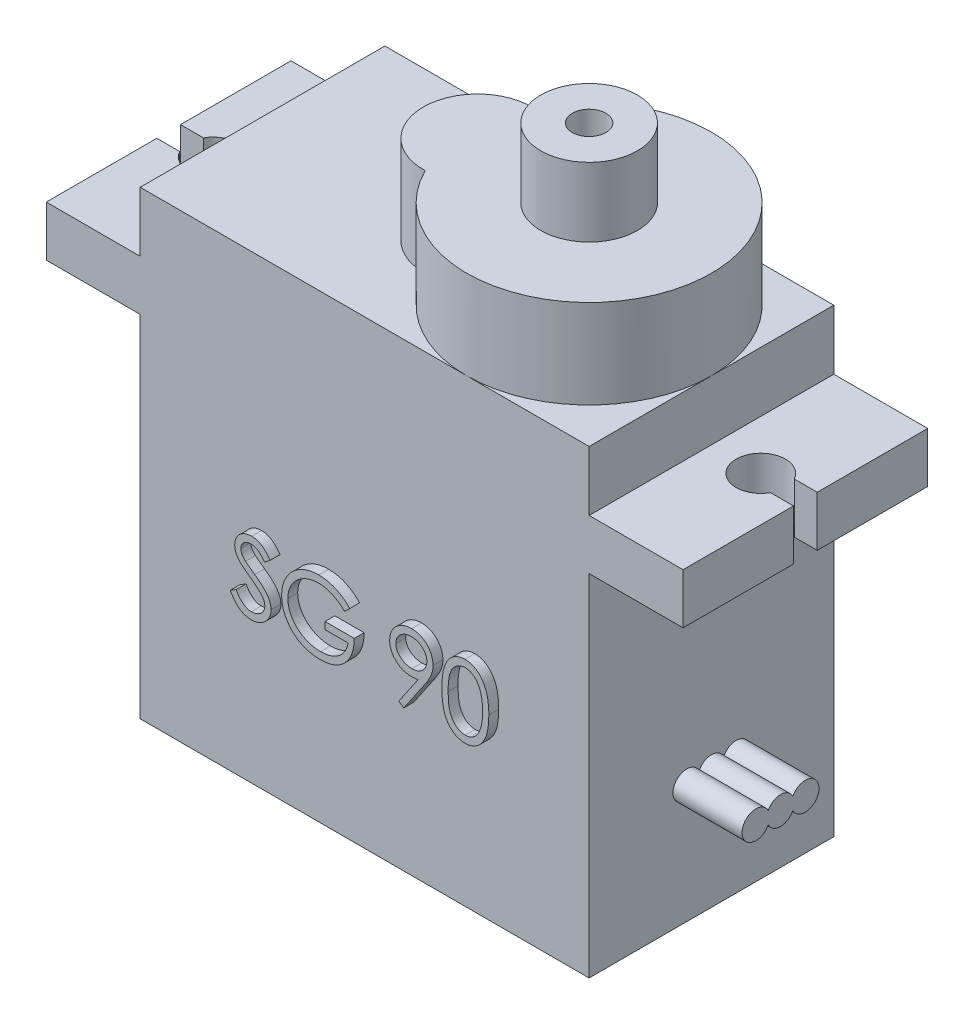
from build123d import *

# Parameters (mm, degrees)
SALIENTE_EXTRUIR1_DEPTH = 6.2
SALIENTE_EXTRUIR2_START = 5.58
CROQUIS2_R              = 6.2
CROQUIS2_R_2            = 2.75
SALIENTE_EXTRUIR2_DEPTH = 4.5
SALIENTE_EXTRUIR3_START = 10.08
CROQUIS3_R              = 2.45
CROQUIS3_R_2            = 0.85
SALIENTE_EXTRUIR3_DEPTH = 3.5
SALIENTE_EXTRUIR5_START = 11.375
CROQUIS4_R              = 0.7
SALIENTE_EXTRUIR5_DEPTH = 3.5
CROQUIS5_R              = 1.25
CROQUIS5_W              = 3.02368951
CROQUIS5_H              = 1.2
CORTAR_EXTRUIR1_DEPTH   = 3.5
CORTAR_EXTRUIR2_START   = -17.75
CORTAR_EXTRUIR2_DEPTH   = 0.5
SALIENTE_EXTRUIR6_START = 6.2
SALIENTE_EXTRUIR6_DEPTH = 0.5


with BuildPart() as part:
    # Croquis1 → Saliente-Extruir1 (new body, symmetric)
    with BuildSketch(Plane.XY):
        Polygon((-11.375, 0), (-16.135, 0), (-16.135, 2.55), (-11.375, 2.55), (-11.375, 5.58), (11.375, 5.58), (11.375, 2.55), (16.135, 2.55), (16.135, 0), (11.375, 0), (11.375, -17.75), (-11.375, -17.75), align=None)
    extrude(amount=SALIENTE_EXTRUIR1_DEPTH, both=True)

    # Croquis2 → Saliente-Extruir2 (add)
    with BuildSketch(Plane(origin=(0, 0, 0), x_dir=(1, 0, 0), z_dir=(0, 1, 0)).offset(SALIENTE_EXTRUIR2_START)):
        with Locations((5.175, 0)):
            Circle(CROQUIS2_R)
        with Locations((-0.475, 0)):
            Circle(CROQUIS2_R_2)
    extrude(amount=SALIENTE_EXTRUIR2_DEPTH)

    # Croquis3 → Saliente-Extruir3 (add)
    with BuildSketch(Plane(origin=(0, 0, 0), x_dir=(1, 0, 0), z_dir=(0, 1, 0)).offset(SALIENTE_EXTRUIR3_START)):
        with Locations((5.175, 0)):
            Circle(CROQUIS3_R)
        with Locations((5.175, 0)):
            Circle(CROQUIS3_R_2, mode=Mode.SUBTRACT)
    extrude(amount=SALIENTE_EXTRUIR3_DEPTH)

    # Croquis4 → Saliente-Extruir5 (add)
    with BuildSketch(Plane(origin=(0, 0, 0), x_dir=(0, 0, -1), z_dir=(1, 0, 0)).offset(SALIENTE_EXTRUIR5_START)):
        with Locations((0, -11.75)):
            Circle(CROQUIS4_R)
        with Locations((1.25, -11.75)):
            Circle(CROQUIS4_R)
        with Locations((-1.25, -11.75)):
            Circle(CROQUIS4_R)
    extrude(amount=SALIENTE_EXTRUIR5_DEPTH)

    # Croquis5 → Cortar-Extruir1 (cut)
    with BuildSketch(Plane(origin=(0, 0, 0), x_dir=(1, 0, 0), z_dir=(0, 1, 0))):
        with Locations((-13.875, 0)):
            Circle(CROQUIS5_R)
        with Locations((-16.135, 0)):
            Rectangle(CROQUIS5_W, CROQUIS5_H)
    cortar_extruir1 = extrude(amount=CORTAR_EXTRUIR1_DEPTH, mode=Mode.SUBTRACT)

    # Simetría1: Cortar-Extruir1 across plane
    add(cortar_extruir1.mirror(Plane(origin=(0, 0, 0), x_dir=(0, 0, 1), z_dir=(1, 0, 0))), mode=Mode.SUBTRACT)

    # Croquis6 → Cortar-Extruir2 (cut)
    with BuildSketch(Plane(origin=(0, 0, 0), x_dir=(1, 0, 0), z_dir=(0, 1, 0)).offset(CORTAR_EXTRUIR2_START)):
        Polygon((1.883315853, 1.665238112), (1.569213289, 1.665238112), (1.569213289, -1.475787529), (0.223059443, -1.475787529), (0.223059443, -1.834761888), (1.883315853, -1.834761888), align=None)
        Polygon((-0.180786711, -1.834761888), (-0.642825974, 1.665238112), (-0.687697769, 1.665238112), (-2.132709788, -1.20655676), (-3.574216198, 1.665238112), (-3.619789115, 1.665238112), (-4.084632865, -1.834761888), (-3.769128057, -1.834761888), (-3.433991839, 0.683667599), (-2.170570365, -1.834761888), (-2.099757064, -1.834761888), (-0.831427737, 0.689276573), (-0.496992641, -1.834761888), align=None)
    extrude(amount=CORTAR_EXTRUIR2_DEPTH, mode=Mode.SUBTRACT)

    # Croquis7 → Saliente-Extruir6 (add)
    with BuildSketch(Plane.XY.offset(SALIENTE_EXTRUIR6_START)):
        with BuildLine():
            Line((-6.31025641, -9.324819712), (-6.014383013, -9.147435897))
            add(Edge.make_bspline(
                [(-6.014383013, -9.147435897), (-5.986864776, -9.193500282), (-5.934140895, -9.281757866), (-5.846189536, -9.401015907), (-5.755056625, -9.502378063), (-5.660067291, -9.585254671), (-5.561801343, -9.650503558), (-5.459617289, -9.696705789), (-5.353859479, -9.725521765), (-5.281885657, -9.729021851), (-5.245953526, -9.730769231)],
                knots=[0, 0, 0, 0, 0.000160901, 0.00030828, 0.000443778, 0.00056903, 0.000685513, 0.000796284, 0.00090427, 0.001011928, 0.001011928, 0.001011928, 0.001011928], degree=3))
            add(Edge.make_bspline(
                [(-5.245953526, -9.730769231), (-5.215266665, -9.729914558), (-5.154429892, -9.728220168), (-5.064867649, -9.711939366), (-4.977885847, -9.686927237), (-4.895277209, -9.651106306), (-4.818181595, -9.60776782), (-4.750574899, -9.555421642), (-4.692128786, -9.496815437), (-4.644319672, -9.431432782), (-4.607639636, -9.361115633), (-4.579447568, -9.288939682), (-4.563802494, -9.213771114), (-4.561445741, -9.163160651), (-4.56025641, -9.137620192)],
                knots=[0, 0, 0, 0, 9.1978e-05, 0.000182347, 0.000272202, 0.000362975, 0.000451852, 0.000536835, 0.000618639, 0.000699414, 0.000778765, 0.000855983, 0.0009312, 0.001007828, 0.001007828, 0.001007828, 0.001007828], degree=3))
            add(Edge.make_bspline(
                [(-4.56025641, -9.137620192), (-4.561730721, -9.108479343), (-4.564727779, -9.049240253), (-4.590059259, -8.9618406), (-4.629908506, -8.87534803), (-4.66667115, -8.821846765), (-4.685757212, -8.794070513)],
                knots=[0, 0, 0, 0, 8.7281e-05, 0.000177429, 0.000270909, 0.000371844, 0.000371844, 0.000371844, 0.000371844], degree=3))
            add(Edge.make_bspline(
                [(-4.685757212, -8.794070513), (-4.701427826, -8.774023689), (-4.73432632, -8.731937891), (-4.790883833, -8.669292655), (-4.857249947, -8.604674236), (-4.931153502, -8.535615179), (-5.015286591, -8.465327383), (-5.107014105, -8.390459105), (-5.208677964, -8.313857528), (-5.279977461, -8.262484962), (-5.316766827, -8.235977564)],
                knots=[0, 0, 0, 0, 7.6319e-05, 0.000160223, 0.000252933, 0.000354147, 0.000463581, 0.000581729, 0.000709336, 0.000845369, 0.000845369, 0.000845369, 0.000845369], degree=3))
            add(Edge.make_bspline(
                [(-5.316766827, -8.235977564), (-5.353590823, -8.209748976), (-5.4239955, -8.159601914), (-5.522454082, -8.08517763), (-5.610498545, -8.017133761), (-5.687737562, -7.954829749), (-5.754137158, -7.898257144), (-5.810220569, -7.847959205), (-5.854559127, -7.802575644), (-5.879214707, -7.773134302), (-5.890284455, -7.759915865)],
                knots=[0, 0, 0, 0, 0.000135623, 0.000259301, 0.000370234, 0.000469439, 0.00055697, 0.000631911, 0.000695377, 0.00074709, 0.00074709, 0.00074709, 0.00074709], degree=3))
            add(Edge.make_bspline(
                [(-5.890284455, -7.759915865), (-5.905757, -7.739314829), (-5.936185837, -7.698800125), (-5.976351843, -7.635475267), (-6.010491005, -7.570652002), (-6.037253337, -7.504156137), (-6.059789556, -7.436921208), (-6.074947487, -7.368069962), (-6.084438884, -7.297911344), (-6.08541087, -7.250697843), (-6.085897436, -7.227063301)],
                knots=[0, 0, 0, 0, 7.727e-05, 0.000151962, 0.000224716, 0.000296717, 0.00036678, 0.0004372, 0.000507902, 0.000578771, 0.000578771, 0.000578771, 0.000578771], degree=3))
            add(Edge.make_bspline(
                [(-6.085897436, -7.227063301), (-6.084592227, -7.190033527), (-6.082009707, -7.116765463), (-6.06016919, -7.009734633), (-6.025696296, -6.907548215), (-5.977401408, -6.811217882), (-5.915144055, -6.723251901), (-5.843098081, -6.642638414), (-5.757286595, -6.574869832), (-5.663133971, -6.515657773), (-5.560077599, -6.469311848), (-5.452086696, -6.434350868), (-5.338989624, -6.41454161), (-5.262386489, -6.411698845), (-5.223517628, -6.41025641)],
                knots=[0, 0, 0, 0, 0.000110999, 0.000219625, 0.000326272, 0.00043382, 0.000541574, 0.000648775, 0.000756959, 0.000868438, 0.000981703, 0.00109501, 0.001208203, 0.0013248, 0.0013248, 0.0013248, 0.0013248], degree=3))
            add(Edge.make_bspline(
                [(-5.223517628, -6.41025641), (-5.182273528, -6.411678962), (-5.100252176, -6.414507963), (-4.979602961, -6.439105494), (-4.863442244, -6.479806166), (-4.769998979, -6.525994824), (-4.696866218, -6.57212624), (-4.641093485, -6.614146064), (-4.584576034, -6.662521173), (-4.52685798, -6.717380419), (-4.46891732, -6.77922717), (-4.409893868, -6.847637859), (-4.349649599, -6.922194415), (-4.310893739, -6.975418915), (-4.291025641, -7.002704327)],
                knots=[0, 0, 0, 0, 0.000123638, 0.000245877, 0.000367608, 0.000492088, 0.000557638, 0.000626769, 0.000701372, 0.00078072, 0.000865532, 0.000955497, 0.001051745, 0.001152989, 0.001152989, 0.001152989, 0.001152989], degree=3))
            Line((-4.291025641, -7.002704327), (-4.574979968, -7.217948718))
            add(Edge.make_bspline(
                [(-4.574979968, -7.217948718), (-4.5921259, -7.195860028), (-4.625144957, -7.153322374), (-4.675274444, -7.093751059), (-4.722523092, -7.039334579), (-4.769073492, -6.992069451), (-4.812467124, -6.949367318), (-4.854584166, -6.912807561), (-4.894818517, -6.882031966), (-4.945535428, -6.849188406), (-5.009253146, -6.816631902), (-5.089237682, -6.789082824), (-5.172823957, -6.772527762), (-5.229753589, -6.770338874), (-5.258573718, -6.769230769)],
                knots=[0, 0, 0, 0, 8.3877e-05, 0.000161528, 0.000233552, 0.000299993, 0.000360485, 0.000416152, 0.000467195, 0.000512312, 0.000597287, 0.000681099, 0.000765389, 0.000851809, 0.000851809, 0.000851809, 0.000851809], degree=3))
            add(Edge.make_bspline(
                [(-5.258573718, -6.769230769), (-5.29473024, -6.770442469), (-5.364454688, -6.772779118), (-5.463444924, -6.798299104), (-5.552538849, -6.838480964), (-5.629091414, -6.894795942), (-5.692828391, -6.961516935), (-5.73893385, -7.03829579), (-5.766684014, -7.123078192), (-5.770070294, -7.182219849), (-5.771794872, -7.212339744)],
                knots=[0, 0, 0, 0, 0.000108248, 0.000208746, 0.00030443, 0.000399793, 0.000492054, 0.00057947, 0.000666386, 0.000756591, 0.000756591, 0.000756591, 0.000756591], degree=3))
            add(Edge.make_bspline(
                [(-5.771794872, -7.212339744), (-5.771401745, -7.231091222), (-5.770614849, -7.268624842), (-5.759640051, -7.324076264), (-5.745540722, -7.379387603), (-5.723198091, -7.434310186), (-5.692352787, -7.489804545), (-5.651847611, -7.546826282), (-5.600834299, -7.605877991), (-5.561757287, -7.644285365), (-5.541125801, -7.664563301)],
                knots=[0, 0, 0, 0, 5.616e-05, 0.000112411, 0.000169046, 0.000227244, 0.000289691, 0.000359134, 0.000436702, 0.000523463, 0.000523463, 0.000523463, 0.000523463], degree=3))
            add(Edge.make_bspline(
                [(-5.541125801, -7.664563301), (-5.533464429, -7.671400327), (-5.515262762, -7.687643535), (-5.481986836, -7.714235816), (-5.438044038, -7.747038588), (-5.384581837, -7.787625905), (-5.320614475, -7.834707367), (-5.246134919, -7.887680979), (-5.161973386, -7.948266438), (-5.10225147, -7.990623979), (-5.070673077, -8.013020833)],
                knots=[0, 0, 0, 0, 3.0802e-05, 7.3177e-05, 0.000127725, 0.000195314, 0.000274544, 0.000365991, 0.000469501, 0.000585644, 0.000585644, 0.000585644, 0.000585644], degree=3))
            add(Edge.make_bspline(
                [(-5.070673077, -8.013020833), (-5.032687164, -8.040662193), (-4.959132707, -8.094185855), (-4.854475127, -8.174601535), (-4.759581319, -8.253249303), (-4.674118116, -8.32962691), (-4.597241207, -8.403155003), (-4.529803487, -8.474718184), (-4.471117806, -8.543803756), (-4.407938588, -8.632376332), (-4.343380768, -8.741157416), (-4.287939261, -8.874435655), (-4.252980913, -9.008231975), (-4.248409398, -9.098158812), (-4.246153846, -9.142528045)],
                knots=[0, 0, 0, 0, 0.000140932, 0.000272896, 0.000395881, 0.000510584, 0.000616697, 0.000714904, 0.000805482, 0.000888372, 0.001041088, 0.001183793, 0.001320341, 0.001453327, 0.001453327, 0.001453327, 0.001453327], degree=3))
            add(Edge.make_bspline(
                [(-4.246153846, -9.142528045), (-4.246810984, -9.17390641), (-4.248112499, -9.236053794), (-4.263073413, -9.32730887), (-4.284993078, -9.41593974), (-4.318030312, -9.500850853), (-4.35835347, -9.583595615), (-4.409519718, -9.662003516), (-4.468827403, -9.737809914), (-4.536861168, -9.808993406), (-4.61130707, -9.874339602), (-4.689990765, -9.932468663), (-4.773041038, -9.980936986), (-4.860007355, -10.020487828), (-4.950909691, -10.051421346), (-5.045717475, -10.073834215), (-5.144586986, -10.087589926), (-5.211787468, -10.089017687), (-5.245953526, -10.08974359)],
                knots=[0, 0, 0, 0, 9.4044e-05, 0.000186263, 0.000276729, 0.000367488, 0.000459046, 0.000552398, 0.000647774, 0.000747454, 0.000847311, 0.000944634, 0.001040472, 0.001135227, 0.001230788, 0.001328063, 0.00142712, 0.00152957, 0.00152957, 0.00152957, 0.00152957], degree=3))
            add(Edge.make_bspline(
                [(-5.245953526, -10.08974359), (-5.272388869, -10.089232408), (-5.324926629, -10.088216483), (-5.402636111, -10.079235202), (-5.4787757, -10.066528099), (-5.552389982, -10.046354029), (-5.624427393, -10.021877052), (-5.694574628, -9.991738719), (-5.762865682, -9.955621518), (-5.829683265, -9.914326493), (-5.894857439, -9.866268748), (-5.957776907, -9.810295252), (-6.020506093, -9.747949747), (-6.081193489, -9.677539184), (-6.141066633, -9.600201101), (-6.198945043, -9.515211917), (-6.256026761, -9.423034564), (-6.291842228, -9.358169478), (-6.31025641, -9.324819712)],
                knots=[0, 0, 0, 0, 7.9276e-05, 0.000157554, 0.000234438, 0.000310629, 0.000386236, 0.000462555, 0.000539392, 0.000617798, 0.000698008, 0.000781971, 0.000870217, 0.00096315, 0.001060616, 0.001163492, 0.001271478, 0.00138575, 0.00138575, 0.00138575, 0.00138575], degree=3))
        make_face()
        with BuildLine():
            Line((-0.252564103, -7.097355769), (-0.521794872, -7.352564103))
            add(Edge.make_bspline(
                [(-0.521794872, -7.352564103), (-0.57051376, -7.30673324), (-0.666789806, -7.216164377), (-0.823750049, -7.098653381), (-0.987513683, -6.997987281), (-1.15722618, -6.916081045), (-1.328684734, -6.850728284), (-1.49961351, -6.804200144), (-1.668259211, -6.774527607), (-1.78042643, -6.770979237), (-1.835697115, -6.769230769)],
                knots=[0, 0, 0, 0, 0.000200536, 0.000396289, 0.000586999, 0.000776397, 0.000960787, 0.001136655, 0.001307246, 0.001472961, 0.001472961, 0.001472961, 0.001472961], degree=3))
            add(Edge.make_bspline(
                [(-1.835697115, -6.769230769), (-1.869611815, -6.769644375), (-1.937353256, -6.770470514), (-2.0379752, -6.781014729), (-2.137541837, -6.796179594), (-2.235865212, -6.818121471), (-2.333136498, -6.845930531), (-2.42901739, -6.880715994), (-2.523686745, -6.921271238), (-2.616252826, -6.968133712), (-2.70599333, -7.019613558), (-2.790750165, -7.076662099), (-2.871063564, -7.137450889), (-2.94542399, -7.203501868), (-3.014259176, -7.274216734), (-3.079207548, -7.34828004), (-3.137984844, -7.427715258), (-3.191076009, -7.511060884), (-3.238437627, -7.596853074), (-3.280246281, -7.684266063), (-3.315343369, -7.773009918), (-3.343112824, -7.863195995), (-3.366023478, -7.954126585), (-3.382141085, -8.046431306), (-3.391227808, -8.140208991), (-3.392799588, -8.20300625), (-3.393589744, -8.234575321)],
                knots=[0, 0, 0, 0, 0.000101701, 0.000203139, 0.000303193, 0.000403728, 0.000505139, 0.000606491, 0.000709509, 0.000813922, 0.000917583, 0.001019673, 0.001120217, 0.001219549, 0.001317716, 0.001416124, 0.001514842, 0.00161384, 0.001712379, 0.001808658, 0.001904353, 0.001998376, 0.002091562, 0.002185504, 0.002279198, 0.002373914, 0.002373914, 0.002373914, 0.002373914], degree=3))
            add(Edge.make_bspline(
                [(-3.393589744, -8.234575321), (-3.392834025, -8.266846138), (-3.391324652, -8.331299651), (-3.381664333, -8.427493724), (-3.363736092, -8.522259126), (-3.339768384, -8.615907259), (-3.309787568, -8.708598507), (-3.272414902, -8.799931017), (-3.228149301, -8.889901408), (-3.176912749, -8.977699025), (-3.120726546, -9.063222049), (-3.057783465, -9.14378157), (-2.990922881, -9.220450348), (-2.917708981, -9.291526111), (-2.840489439, -9.358910008), (-2.756957163, -9.42074553), (-2.668754703, -9.478223753), (-2.575747491, -9.530620272), (-2.478944708, -9.577428808), (-2.379687955, -9.619052704), (-2.27766014, -9.653332041), (-2.17339745, -9.681270145), (-2.067024178, -9.704170443), (-1.958000376, -9.718902923), (-1.847127667, -9.729593754), (-1.772389035, -9.730375424), (-1.734735577, -9.730769231)],
                knots=[0, 0, 0, 0, 9.6818e-05, 0.000193372, 0.000289633, 0.000385881, 0.000483216, 0.000581645, 0.00068167, 0.000783767, 0.00088644, 0.000988395, 0.001090231, 0.001191373, 0.001294266, 0.001397472, 0.001502873, 0.001609927, 0.001717482, 0.001825293, 0.001932604, 0.002040093, 0.002149, 0.002258763, 0.002369974, 0.002482889, 0.002482889, 0.002482889, 0.002482889], degree=3))
            add(Edge.make_bspline(
                [(-1.734735577, -9.730769231), (-1.68935723, -9.729820654), (-1.600249472, -9.727957971), (-1.46926303, -9.713457681), (-1.343459959, -9.690810888), (-1.223193756, -9.657644991), (-1.108324735, -9.615341316), (-0.998431794, -9.56434593), (-0.894380135, -9.50270287), (-0.795856962, -9.433129003), (-0.705099776, -9.355614171), (-0.623245652, -9.271969716), (-0.551600163, -9.182601649), (-0.489095463, -9.088036334), (-0.437386809, -8.987491029), (-0.394944014, -8.881458466), (-0.362410722, -8.769890954), (-0.349055748, -8.692799323), (-0.342307692, -8.653846154)],
                knots=[0, 0, 0, 0, 0.000136106, 0.000267267, 0.000394882, 0.00051922, 0.000641, 0.000761758, 0.000882124, 0.001003321, 0.001123172, 0.001239687, 0.001353892, 0.00146629, 0.00157918, 0.001692449, 0.001808499, 0.001927028, 0.001927028, 0.001927028, 0.001927028], degree=3))
            Line((-0.342307692, -8.653846154), (-1.508974359, -8.653846154))
            Line((-1.508974359, -8.653846154), (-1.508974359, -8.294871795))
            Line((-1.508974359, -8.294871795), (-0.028205128, -8.294871795))
            add(Edge.make_bspline(
                [(-0.028205128, -8.294871795), (-0.029910977, -8.361779284), (-0.03324963, -8.492729325), (-0.056668546, -8.683699596), (-0.094485058, -8.86407129), (-0.14614537, -9.034034361), (-0.21302065, -9.193347954), (-0.294393179, -9.34217382), (-0.3915653, -9.479550501), (-0.501075741, -9.606599505), (-0.623975699, -9.719928717), (-0.756944319, -9.819534655), (-0.900201287, -9.90343727), (-1.053611095, -9.971697933), (-1.216671528, -10.024971927), (-1.389759908, -10.062743504), (-1.572641509, -10.085373467), (-1.697978186, -10.088264847), (-1.762079327, -10.08974359)],
                knots=[0, 0, 0, 0, 0.000200697, 0.000392801, 0.000576238, 0.000752994, 0.000924878, 0.001093697, 0.001260784, 0.001428776, 0.001595974, 0.001761299, 0.001926279, 0.002092931, 0.002264096, 0.002439994, 0.002623661, 0.002815923, 0.002815923, 0.002815923, 0.002815923], degree=3))
            add(Edge.make_bspline(
                [(-1.762079327, -10.08974359), (-1.801589462, -10.089174469), (-1.879516183, -10.088051978), (-1.994607111, -10.080074631), (-2.106524732, -10.067794054), (-2.215252741, -10.049248931), (-2.321191083, -10.026534277), (-2.423810668, -9.997447558), (-2.52350241, -9.963778859), (-2.620420395, -9.925483185), (-2.713684942, -9.881111528), (-2.803711459, -9.831801889), (-2.890997585, -9.777808528), (-2.97494875, -9.718197682), (-3.056002371, -9.653415222), (-3.133635815, -9.583331303), (-3.208283693, -9.508160184), (-3.255044157, -9.454781174), (-3.278605769, -9.427884615)],
                knots=[0, 0, 0, 0, 0.000118523, 0.000233765, 0.000345956, 0.000456148, 0.000564516, 0.000670839, 0.000775933, 0.000880089, 0.000983271, 0.001085557, 0.001187895, 0.001290998, 0.001394253, 0.001499002, 0.001604602, 0.001711853, 0.001711853, 0.001711853, 0.001711853], degree=3))
            add(Edge.make_bspline(
                [(-3.278605769, -9.427884615), (-3.312791701, -9.385213962), (-3.380596114, -9.300580945), (-3.46787427, -9.164981001), (-3.542275673, -9.024579141), (-3.602643495, -8.878984512), (-3.649781582, -8.728333299), (-3.683587834, -8.572818008), (-3.703395124, -8.412238378), (-3.706248661, -8.303573113), (-3.707692308, -8.248597756)],
                knots=[0, 0, 0, 0, 0.00016394, 0.000325158, 0.000482912, 0.000640071, 0.000797293, 0.000955853, 0.00111691, 0.001281823, 0.001281823, 0.001281823, 0.001281823], degree=3))
            add(Edge.make_bspline(
                [(-3.707692308, -8.248597756), (-3.70716007, -8.207431504), (-3.706102358, -8.125622196), (-3.693276842, -8.004164889), (-3.674875424, -7.884864197), (-3.647828369, -7.76781764), (-3.613732104, -7.652947049), (-3.571178618, -7.540199085), (-3.521633722, -7.429507213), (-3.464048226, -7.321633345), (-3.399963767, -7.218008932), (-3.330413546, -7.119051129), (-3.254409946, -7.026562064), (-3.173194147, -6.939370416), (-3.085797156, -6.858571569), (-2.993037733, -6.783417458), (-2.89484439, -6.713807272), (-2.79090821, -6.650837438), (-2.682780525, -6.594273817), (-2.570720524, -6.544684605), (-2.454762413, -6.50370129), (-2.335774935, -6.46892751), (-2.212857435, -6.44321237), (-2.086901898, -6.424563624), (-1.957251786, -6.411803025), (-1.869615756, -6.410776769), (-1.825180288, -6.41025641)],
                knots=[0, 0, 0, 0, 0.000123447, 0.000245326, 0.00036601, 0.000485407, 0.000605413, 0.000725221, 0.000846669, 0.000968994, 0.001091771, 0.00121199, 0.001331568, 0.001450618, 0.001569191, 0.001688326, 0.001808545, 0.001929991, 0.002052609, 0.002174413, 0.002297271, 0.002421315, 0.002546037, 0.002673651, 0.002803207, 0.002936466, 0.002936466, 0.002936466, 0.002936466], degree=3))
            add(Edge.make_bspline(
                [(-1.825180288, -6.41025641), (-1.788942045, -6.410835902), (-1.717085866, -6.411984966), (-1.610160134, -6.419949614), (-1.504887119, -6.432573495), (-1.401110729, -6.449800282), (-1.299184363, -6.473263972), (-1.198817658, -6.501342257), (-1.099865121, -6.53403408), (-1.002636872, -6.573022926), (-0.906479156, -6.617276551), (-0.810857316, -6.667089973), (-0.71609807, -6.723314978), (-0.622037088, -6.786118513), (-0.52808123, -6.854421931), (-0.435716588, -6.930178755), (-0.342713644, -7.010401511), (-0.28291183, -7.068083695), (-0.252564103, -7.097355769)],
                knots=[0, 0, 0, 0, 0.00010871, 0.000215559, 0.000321482, 0.000426718, 0.00053098, 0.000635089, 0.000739295, 0.000843451, 0.000949174, 0.001056739, 0.001166761, 0.001279546, 0.001395941, 0.001515076, 0.00163782, 0.001764288, 0.001764288, 0.001764288, 0.001764288], degree=3))
        make_face()
        with BuildLine():
            Line((2.484615385, -10.08974359), (2.233613782, -9.915164263))
            Line((2.233613782, -9.915164263), (3.206770833, -8.492588141))
            add(Edge.make_bspline(
                [(3.206770833, -8.492588141), (3.144680098, -8.500181204), (3.022419978, -8.515132369), (2.899282876, -8.517879024), (2.838681891, -8.519230769)],
                knots=[0, 0, 0, 0, 0.000187529, 0.000369255, 0.000369255, 0.000369255, 0.000369255], degree=3))
            add(Edge.make_bspline(
                [(2.838681891, -8.519230769), (2.801939843, -8.518289693), (2.729818416, -8.516442442), (2.623786764, -8.501800634), (2.521901203, -8.479250506), (2.424431847, -8.445601751), (2.331012342, -8.403783542), (2.241846629, -8.351926528), (2.157054739, -8.290920237), (2.077547329, -8.221087245), (2.00523559, -8.144409193), (1.940812292, -8.06325355), (1.88727116, -7.976677579), (1.842794575, -7.886447359), (1.809064121, -7.791266009), (1.784501583, -7.692216608), (1.769379229, -7.588604966), (1.767580134, -7.518079836), (1.766666667, -7.482271635)],
                knots=[0, 0, 0, 0, 0.000110185, 0.000216284, 0.000320547, 0.000422759, 0.000525058, 0.000627155, 0.000731643, 0.000837964, 0.0009441, 0.00104747, 0.001148247, 0.001248901, 0.001348697, 0.001450555, 0.001554666, 0.00166205, 0.00166205, 0.00166205, 0.00166205], degree=3))
            add(Edge.make_bspline(
                [(1.766666667, -7.482271635), (1.768401101, -7.433302982), (1.771805445, -7.33718745), (1.799203962, -7.196753681), (1.844264302, -7.063967138), (1.907092678, -6.939176944), (1.9862274, -6.824178205), (2.08133599, -6.720569595), (2.191839954, -6.629824742), (2.315221973, -6.551820664), (2.448574994, -6.489085667), (2.588243652, -6.442846366), (2.733157772, -6.415647619), (2.831325442, -6.412061757), (2.880749199, -6.41025641)],
                knots=[0, 0, 0, 0, 0.000146818, 0.000288173, 0.000427413, 0.000566316, 0.000705952, 0.000844895, 0.000986821, 0.001133677, 0.001281714, 0.001427825, 0.001574003, 0.00172222, 0.00172222, 0.00172222, 0.00172222], degree=3))
            add(Edge.make_bspline(
                [(2.880749199, -6.41025641), (2.929237618, -6.412086573), (3.025046165, -6.415702803), (3.165935172, -6.442186772), (3.300876189, -6.486823445), (3.429121175, -6.548508009), (3.547860588, -6.625828916), (3.654636399, -6.71796344), (3.747011938, -6.824968967), (3.824835819, -6.944257457), (3.887305859, -7.072424439), (3.932378142, -7.206208361), (3.960123781, -7.344647082), (3.963620108, -7.438441556), (3.965384615, -7.485777244)],
                knots=[0, 0, 0, 0, 0.000145418, 0.000287333, 0.000428343, 0.000570713, 0.000713061, 0.00085223, 0.000992387, 0.001135706, 0.001278381, 0.001418948, 0.001558239, 0.001700158, 0.001700158, 0.001700158, 0.001700158], degree=3))
            add(Edge.make_bspline(
                [(3.965384615, -7.485777244), (3.964206206, -7.522521011), (3.961816099, -7.597046551), (3.945079792, -7.710276894), (3.916659606, -7.825728124), (3.884407908, -7.923449719), (3.85327574, -8.004158169), (3.823974608, -8.067909749), (3.791462455, -8.135011013), (3.753543689, -8.20475835), (3.712781393, -8.278040885), (3.666722116, -8.354123601), (3.616416544, -8.433108594), (3.580586825, -8.486355682), (3.562239583, -8.513621795)],
                knots=[0, 0, 0, 0, 0.000110219, 0.000223552, 0.000342587, 0.000466527, 0.000532018, 0.000601997, 0.000676938, 0.00075567, 0.000840114, 0.000928491, 0.001022434, 0.001121023, 0.001121023, 0.001121023, 0.001121023], degree=3))
            Line((3.562239583, -8.513621795), (2.484615385, -10.08974359))
        make_face()
        with BuildLine():
            add(Edge.make_bspline(
                [(2.896875, -8.16025641), (2.924709014, -8.159496026), (2.978892377, -8.158015818), (3.058269676, -8.149006576), (3.13319388, -8.13303259), (3.203865129, -8.110112878), (3.270992031, -8.082456209), (3.333508359, -8.047244223), (3.391466434, -8.005227588), (3.445254361, -7.958017572), (3.493018361, -7.905566989), (3.535561392, -7.850669882), (3.571721959, -7.793085272), (3.600285236, -7.73209201), (3.623769812, -7.669174801), (3.639987824, -7.603320446), (3.648972157, -7.534872045), (3.650503732, -7.488373387), (3.651282051, -7.46474359)],
                knots=[0, 0, 0, 0, 8.3507e-05, 0.00016256, 0.000239294, 0.000312908, 0.000385178, 0.000456751, 0.000527578, 0.000599603, 0.000671055, 0.000740051, 0.000807755, 0.000874553, 0.000941763, 0.001008931, 0.001077548, 0.001148448, 0.001148448, 0.001148448, 0.001148448], degree=3))
            add(Edge.make_bspline(
                [(3.651282051, -7.46474359), (3.650612382, -7.441103925), (3.649292717, -7.394519065), (3.638705417, -7.325969325), (3.620080194, -7.260276064), (3.595089709, -7.197079634), (3.562169471, -7.136899262), (3.522665986, -7.07897939), (3.475733536, -7.023687262), (3.42173097, -6.972323279), (3.363496417, -6.92497538), (3.301435917, -6.883189304), (3.236061001, -6.848168107), (3.167770511, -6.819269137), (3.096422162, -6.796717362), (3.022058174, -6.780499997), (2.944302768, -6.771528243), (2.891521482, -6.770006348), (2.864623397, -6.769230769)],
                knots=[0, 0, 0, 0, 7.09e-05, 0.000139717, 0.000207422, 0.000275384, 0.000343146, 0.000412766, 0.000485392, 0.000560268, 0.000636041, 0.000710323, 0.000784354, 0.000858188, 0.000932471, 0.001008519, 0.001086179, 0.001166885, 0.001166885, 0.001166885, 0.001166885], degree=3))
            add(Edge.make_bspline(
                [(2.864623397, -6.769230769), (2.837959244, -6.770007601), (2.785644395, -6.771531738), (2.708580235, -6.780482943), (2.634719068, -6.796826428), (2.563577447, -6.819258691), (2.495288987, -6.848170263), (2.429917154, -6.883191139), (2.367842137, -6.924965761), (2.309663416, -6.972360533), (2.255565494, -7.02344818), (2.209439965, -7.079221608), (2.169846073, -7.136869133), (2.13697107, -7.197087641), (2.111968553, -7.260273927), (2.093346552, -7.325969904), (2.082758386, -7.394518914), (2.08143884, -7.441103874), (2.080769231, -7.46474359)],
                knots=[0, 0, 0, 0, 8.0005e-05, 0.000156969, 0.000232332, 0.000306614, 0.000380449, 0.000454479, 0.000528762, 0.000604535, 0.000679411, 0.000751586, 0.000821205, 0.000888968, 0.00095693, 0.001024634, 0.001093451, 0.001164351, 0.001164351, 0.001164351, 0.001164351], degree=3))
            add(Edge.make_bspline(
                [(2.080769231, -7.46474359), (2.081375157, -7.488391788), (2.082570154, -7.535030365), (2.094097944, -7.603556758), (2.113376224, -7.669244952), (2.139195614, -7.732733659), (2.173197204, -7.793405517), (2.214921052, -7.850972879), (2.263826598, -7.906088329), (2.319260086, -7.957895541), (2.379928247, -8.005447716), (2.444724993, -8.046978098), (2.51253483, -8.082050543), (2.583596461, -8.110191927), (2.657383261, -8.13280359), (2.734558392, -8.148977135), (2.814866629, -8.157929402), (2.869276611, -8.159473299), (2.896875, -8.16025641)],
                knots=[0, 0, 0, 0, 7.09e-05, 0.000139828, 0.000207725, 0.00027595, 0.000345002, 0.000415829, 0.000488844, 0.000565728, 0.000643147, 0.000719775, 0.000796287, 0.0008718, 0.000948761, 0.001027552, 0.001107998, 0.001190805, 0.001190805, 0.001190805, 0.001190805], degree=3))
        make_face(mode=Mode.SUBTRACT)
        with BuildLine():
            add(Edge.make_bspline(
                [(4.414102564, -8.251402244), (4.414430582, -8.195304856), (4.415067762, -8.086334872), (4.422156183, -7.92755023), (4.433931526, -7.778589941), (4.450068898, -7.639446875), (4.469706879, -7.51008511), (4.495922365, -7.390850353), (4.525735168, -7.281190746), (4.560287614, -7.180748698), (4.599275403, -7.088170995), (4.641709663, -7.001745793), (4.689274458, -6.921603861), (4.739251371, -6.846466071), (4.793663442, -6.777562376), (4.850962233, -6.713919713), (4.913384109, -6.657008963), (4.978807117, -6.605162661), (5.047823582, -6.559713189), (5.118466248, -6.51968045), (5.191221354, -6.485480583), (5.266287537, -6.458590147), (5.342990095, -6.4363793), (5.421597161, -6.421190353), (5.502238525, -6.411633444), (5.55666996, -6.410719776), (5.58427484, -6.41025641)],
                knots=[0, 0, 0, 0, 0.000168282, 0.000326891, 0.000476705, 0.00061646, 0.000747059, 0.00086904, 0.000982494, 0.001087814, 0.001187428, 0.001283689, 0.001376399, 0.001466822, 0.001554203, 0.001639568, 0.001723424, 0.001807301, 0.001889751, 0.001971063, 0.002050735, 0.002130583, 0.002210036, 0.002290062, 0.002370508, 0.002453288, 0.002453288, 0.002453288, 0.002453288], degree=3))
            add(Edge.make_bspline(
                [(5.58427484, -6.41025641), (5.612110318, -6.410744225), (5.667466327, -6.411714336), (5.749306702, -6.421038279), (5.829256384, -6.436509402), (5.906974523, -6.458430377), (5.983099509, -6.485626053), (6.057035917, -6.51971317), (6.129242999, -6.559392038), (6.198573286, -6.606015915), (6.265787901, -6.657998191), (6.329235864, -6.71676086), (6.38892295, -6.781710579), (6.445598256, -6.852152443), (6.497653853, -6.929437528), (6.547227285, -7.012221638), (6.591599321, -7.101952503), (6.634333996, -7.19713297), (6.671220983, -7.300396629), (6.704487228, -7.41116139), (6.731366197, -7.530735577), (6.753755469, -7.658491822), (6.771100365, -7.794899305), (6.783733007, -7.939665621), (6.790406092, -8.092886011), (6.791662793, -8.19764386), (6.792307692, -8.251402244)],
                knots=[0, 0, 0, 0, 8.3481e-05, 0.000166017, 0.000246731, 0.000327534, 0.000408041, 0.000488986, 0.000571522, 0.000654944, 0.000739373, 0.000826202, 0.000914021, 0.001003809, 0.001097153, 0.001193347, 0.001293057, 0.001397277, 0.001506176, 0.001621751, 0.001744038, 0.001873599, 0.002010742, 0.002156422, 0.002309427, 0.002470709, 0.002470709, 0.002470709, 0.002470709], degree=3))
            add(Edge.make_bspline(
                [(6.792307692, -8.251402244), (6.791656108, -8.304926152), (6.790386522, -8.409215303), (6.783807815, -8.561746279), (6.770849184, -8.705744322), (6.754639196, -8.841554784), (6.732188233, -8.968612403), (6.704583066, -9.087356852), (6.673932744, -9.198300923), (6.636097949, -9.300535735), (6.594687239, -9.395487458), (6.549632043, -9.484154606), (6.501362217, -9.567320899), (6.448773472, -9.644320646), (6.392720059, -9.715699303), (6.33200227, -9.780196926), (6.268331685, -9.839367598), (6.200919269, -9.892019225), (6.130507718, -9.93810403), (6.058548641, -9.97931788), (5.983765257, -10.012550575), (5.907852305, -10.041085616), (5.829723939, -10.062886068), (5.749477548, -10.077959923), (5.667521312, -10.088531772), (5.612119747, -10.089338252), (5.58427484, -10.08974359)],
                knots=[0, 0, 0, 0, 0.000160581, 0.000312886, 0.000457868, 0.000594226, 0.000723097, 0.000844701, 0.000959884, 0.001068125, 0.001171421, 0.001270505, 0.001366343, 0.001459687, 0.001550023, 0.00163832, 0.001725149, 0.001810562, 0.001894568, 0.001977446, 0.00205903, 0.002139777, 0.00222058, 0.002301983, 0.002384599, 0.00246808, 0.00246808, 0.00246808, 0.00246808], degree=3))
            add(Edge.make_bspline(
                [(5.58427484, -10.08974359), (5.556670726, -10.089277234), (5.502240801, -10.088357672), (5.421588376, -10.078843941), (5.343305932, -10.063548438), (5.267007178, -10.042131834), (5.192300663, -10.015916997), (5.120204376, -9.981763314), (5.049916693, -9.942429245), (4.981625137, -9.897633823), (4.916612976, -9.84631214), (4.85451437, -9.789547851), (4.796889351, -9.72592444), (4.743255256, -9.656446517), (4.692281167, -9.581753275), (4.645391794, -9.500824902), (4.60202094, -9.413982291), (4.562377449, -9.32066438), (4.527228786, -9.219509453), (4.496181078, -9.109360274), (4.47166692, -8.989244638), (4.450683965, -8.860127271), (4.433759582, -8.721453341), (4.422205257, -8.573147562), (4.415063941, -8.415302353), (4.414428871, -8.307032579), (4.414102564, -8.251402244)],
                knots=[0, 0, 0, 0, 8.278e-05, 0.000163226, 0.000243252, 0.00032184, 0.00040079, 0.000480463, 0.00056082, 0.000642298, 0.000725191, 0.000809047, 0.000894412, 0.000982346, 0.001072188, 0.001165503, 0.001262704, 0.001363236, 0.001469448, 0.001583766, 0.001706286, 0.001836995, 0.001976138, 0.002125253, 0.002283161, 0.002450041, 0.002450041, 0.002450041, 0.002450041], degree=3))
        make_face()
        with BuildLine():
            add(Edge.make_bspline(
                [(4.728205128, -8.25), (4.728324575, -8.296748699), (4.728556399, -8.387478744), (4.734612599, -8.519322005), (4.742862831, -8.642292333), (4.753504128, -8.75654587), (4.769307077, -8.861695882), (4.787013865, -8.958465565), (4.808561954, -9.046342803), (4.834056972, -9.125930613), (4.863096069, -9.198579682), (4.894801933, -9.266180897), (4.928862656, -9.329532833), (4.966981806, -9.388066442), (5.008496869, -9.441972606), (5.052470129, -9.492205438), (5.100542713, -9.537002419), (5.167046455, -9.590729274), (5.25484293, -9.646248408), (5.365463385, -9.694594498), (5.479131836, -9.724976954), (5.556283086, -9.72884071), (5.594791667, -9.730769231)],
                knots=[0, 0, 0, 0, 0.000140231, 0.000272162, 0.000395845, 0.00050998, 0.000616273, 0.00071473, 0.000805025, 0.000887508, 0.000965234, 0.00103957, 0.001111417, 0.001180842, 0.001248855, 0.001315406, 0.001380877, 0.0014457, 0.001571746, 0.00169106, 0.001806864, 0.001922266, 0.001922266, 0.001922266, 0.001922266], degree=3))
            add(Edge.make_bspline(
                [(5.594791667, -9.730769231), (5.633549338, -9.72917145), (5.710984662, -9.725979187), (5.824118457, -9.69518045), (5.933948727, -9.64871091), (6.020020667, -9.593763405), (6.085503211, -9.541435075), (6.132420201, -9.496820427), (6.175482249, -9.44686456), (6.216324324, -9.392965264), (6.2537834, -9.33409278), (6.287846537, -9.270530204), (6.318929885, -9.202101027), (6.336638931, -9.154331287), (6.345693109, -9.129907853)],
                knots=[0, 0, 0, 0, 0.000116044, 0.000231848, 0.000349318, 0.000472837, 0.000536674, 0.000600645, 0.000666733, 0.000734322, 0.000803367, 0.000875831, 0.000950509, 0.001028633, 0.001028633, 0.001028633, 0.001028633], degree=3))
            add(Edge.make_bspline(
                [(6.345693109, -9.129907853), (6.356244877, -9.098678113), (6.377669491, -9.035268349), (6.405281265, -8.936904697), (6.427026664, -8.833701933), (6.44659003, -8.726276816), (6.459943086, -8.613837115), (6.470690899, -8.496730731), (6.477021586, -8.374869369), (6.477806337, -8.292074378), (6.478205128, -8.25)],
                knots=[0, 0, 0, 0, 9.8886e-05, 0.00020078, 0.000306259, 0.000415188, 0.00052824, 0.000645799, 0.000767957, 0.000894177, 0.000894177, 0.000894177, 0.000894177], degree=3))
            add(Edge.make_bspline(
                [(6.478205128, -8.25), (6.477654939, -8.207932427), (6.476578651, -8.125639263), (6.472464664, -8.005121082), (6.461841089, -7.890653321), (6.45004197, -7.781742848), (6.432644749, -7.678992546), (6.413886942, -7.581542241), (6.38868573, -7.490599216), (6.361765955, -7.404739634), (6.330955559, -7.324938979), (6.297039825, -7.250825193), (6.260818066, -7.182040468), (6.221475826, -7.118773527), (6.179480143, -7.060740984), (6.133722594, -7.009106389), (6.086018221, -6.962269421), (6.019201035, -6.908806852), (5.931726745, -6.854295157), (5.822881098, -6.804129397), (5.709610454, -6.775321104), (5.633037, -6.771259417), (5.594791667, -6.769230769)],
                knots=[0, 0, 0, 0, 0.000126219, 0.000246912, 0.000361616, 0.00047102, 0.00057545, 0.000674176, 0.000768567, 0.000858368, 0.000944043, 0.001024988, 0.001102772, 0.001177091, 0.00124833, 0.001317386, 0.001383826, 0.001448649, 0.001573728, 0.001692043, 0.001806995, 0.001921698, 0.001921698, 0.001921698, 0.001921698], degree=3))
            add(Edge.make_bspline(
                [(5.594791667, -6.769230769), (5.556081075, -6.771262216), (5.478589369, -6.77532881), (5.364141414, -6.804022064), (5.254437063, -6.85403503), (5.167194088, -6.908987402), (5.100330301, -6.961325713), (5.053247608, -7.006712167), (5.009101436, -7.056358422), (4.968433736, -7.110760337), (4.930344452, -7.169225704), (4.89536344, -7.232214469), (4.86384611, -7.300045833), (4.834761574, -7.372662268), (4.809188786, -7.452243213), (4.788094823, -7.540012206), (4.76860777, -7.636474098), (4.754812501, -7.742193606), (4.742548745, -7.85647576), (4.734667397, -7.979753078), (4.72853614, -8.111817458), (4.728317675, -8.203016617), (4.728205128, -8.25)],
                knots=[0, 0, 0, 0, 0.000116101, 0.000232413, 0.000351368, 0.000476447, 0.000540832, 0.000605795, 0.000672346, 0.000739935, 0.00080936, 0.000881545, 0.00095588, 0.001033607, 0.001116089, 0.001206384, 0.001304286, 0.001411174, 0.001526077, 0.001649061, 0.001781692, 0.001922624, 0.001922624, 0.001922624, 0.001922624], degree=3))
        make_face(mode=Mode.SUBTRACT)
    extrude(amount=SALIENTE_EXTRUIR6_DEPTH)


solid = part.part
